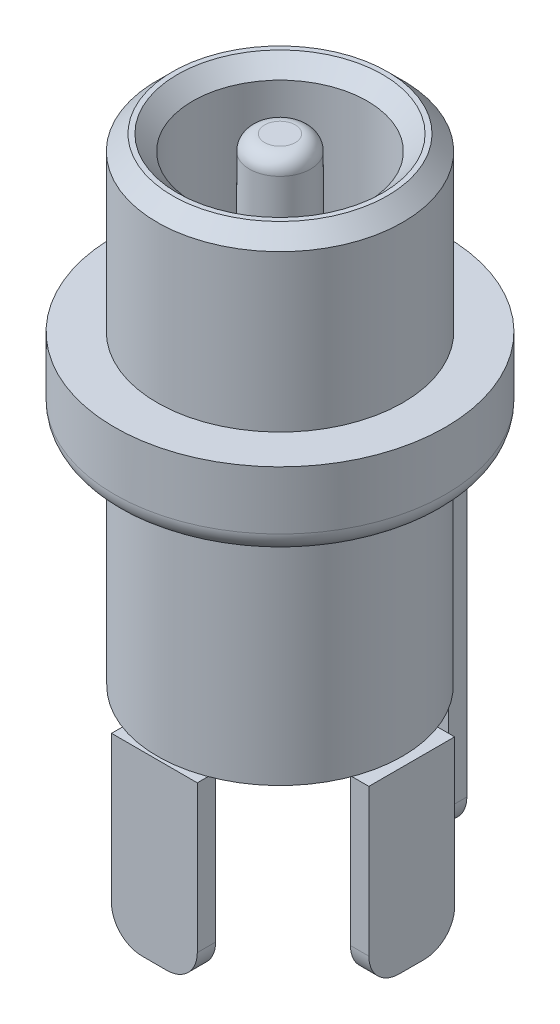
from build123d import *

# Parameters (mm, degrees)
FILLET1_R             = 0.7
SKETCH1_3_W           = 4
SKETCH1_3_H           = 7.4
SKETCH2_R             = 2.85
SKETCH2_R_2           = 1
CUT_EXTRUDE1_DEPTH    = 5.6
FILLET2_R             = 0.5
CHAMFER1_SIZE         = 0.5
SKETCH15_W            = 2.8
SKETCH15_H            = 0.6
BOSS_EXTRUDE1_DEPTH   = 5.8
BOSS_EXTRUDE1_2_DEPTH = 5.8
SKETCH15_W_2          = 0.6
SKETCH15_H_2          = 2.8
BOSS_EXTRUDE1_3_DEPTH = 5.8
SKETCH15_2_W          = 2.8
SKETCH15_2_H          = 0.6
BOSS_EXTRUDE2_DEPTH   = 7.4
FILLET3_R             = 1
FILLET4_R             = 1
FILLET5_R             = 1


with BuildPart() as part:
    # Sketch1 → Revolve1 (revolve)
    with BuildSketch(Plane.XY):
        Polygon((-4, 7.4), (0, 7.4), (0, 15.6), (-4.01, 15.6), (-4.01, 10), (-5.4, 10), (-5.4, 7.4), align=None)
    revolve(axis=Axis((0, 0, 0), (0, 1, 0)))

    # Fillet1
    fillet1_edges = [part.edges().sort_by_distance(p)[0] for p in [
        (5.4, 7.4, 0),
    ]]
    fillet(fillet1_edges, radius=FILLET1_R)

    # Sketch2 → Cut-Extrude1 (cut)
    with BuildSketch(Plane(origin=(0, 15.6, 0), x_dir=(1, 0, 0), z_dir=(0, 1, 0))):
        Circle(SKETCH2_R)
        Circle(SKETCH2_R_2, mode=Mode.SUBTRACT)
    extrude(amount=-CUT_EXTRUDE1_DEPTH, mode=Mode.SUBTRACT)

    # Fillet2
    fillet2_edges = [part.edges().sort_by_distance(p)[0] for p in [
        (-1, 15.6, 0),
    ]]
    fillet(fillet2_edges, radius=FILLET2_R)

    # Chamfer1
    chamfer1_edges = [part.edges().sort_by_distance(p)[0] for p in [
        (-2.85, 15.6, 0),
        (4.01, 15.6, 0),
    ]]
    chamfer(chamfer1_edges, length=CHAMFER1_SIZE)



with BuildPart() as body_2:
    # Sketch1_3 → Revolve2 (revolve)
    with BuildSketch(Plane.XY):
        with Locations((-2, 3.7)):
            Rectangle(SKETCH1_3_W, SKETCH1_3_H)
    revolve(axis=Axis((0, 0, 0), (0, 1, 0)))


with BuildPart() as body_3:
    # Sketch15 → Boss-Extrude1 (new body)
    with BuildSketch(Plane.XZ):
        with Locations((0, 3.8)):
            Rectangle(SKETCH15_W, SKETCH15_H)
    extrude(amount=BOSS_EXTRUDE1_DEPTH)

    # Fillet3
    fillet3_edges = [body_3.edges().sort_by_distance(p)[0] for p in [
        (-1.4, -5.8, 3.8),
        (1.4, -5.8, 3.8),
    ]]
    fillet(fillet3_edges, radius=FILLET3_R)


with BuildPart() as body_4:
    # Sketch15 → Boss-Extrude1 2 (new body)
    with BuildSketch(Plane.XZ):
        with Locations((0, -4.4)):
            Rectangle(SKETCH15_W, SKETCH15_H)
    extrude(amount=BOSS_EXTRUDE1_2_DEPTH)


with BuildPart() as body_5:
    # Sketch15 → Boss-Extrude1 3 (new body)
    with BuildSketch(Plane.XZ):
        with Locations((4, 0)):
            Rectangle(SKETCH15_W_2, SKETCH15_H_2)
    extrude(amount=BOSS_EXTRUDE1_3_DEPTH)

    # Fillet5
    fillet5_edges = [body_5.edges().sort_by_distance(p)[0] for p in [
        (4, -5.8, -1.4),
        (4, -5.8, 1.4),
    ]]
    fillet(fillet5_edges, radius=FILLET5_R)


with BuildPart() as part_1:
    add(part.part)

    add(body_4.part)  # Boss-Extrude2 merges body 4
    # Sketch15_2 → Boss-Extrude2 (add)
    with BuildSketch(Plane.XZ):
        with Locations((0, -4.4)):
            Rectangle(SKETCH15_2_W, SKETCH15_2_H)
    extrude(amount=-BOSS_EXTRUDE2_DEPTH)

    # Fillet4
    fillet4_edges = [part_1.edges().sort_by_distance(p)[0] for p in [
        (1.4, -5.8, -4.4),
        (-1.4, -5.8, -4.4),
    ]]
    fillet(fillet4_edges, radius=FILLET4_R)


solid = Compound([body_2.part, body_3.part, body_5.part, part_1.part])
